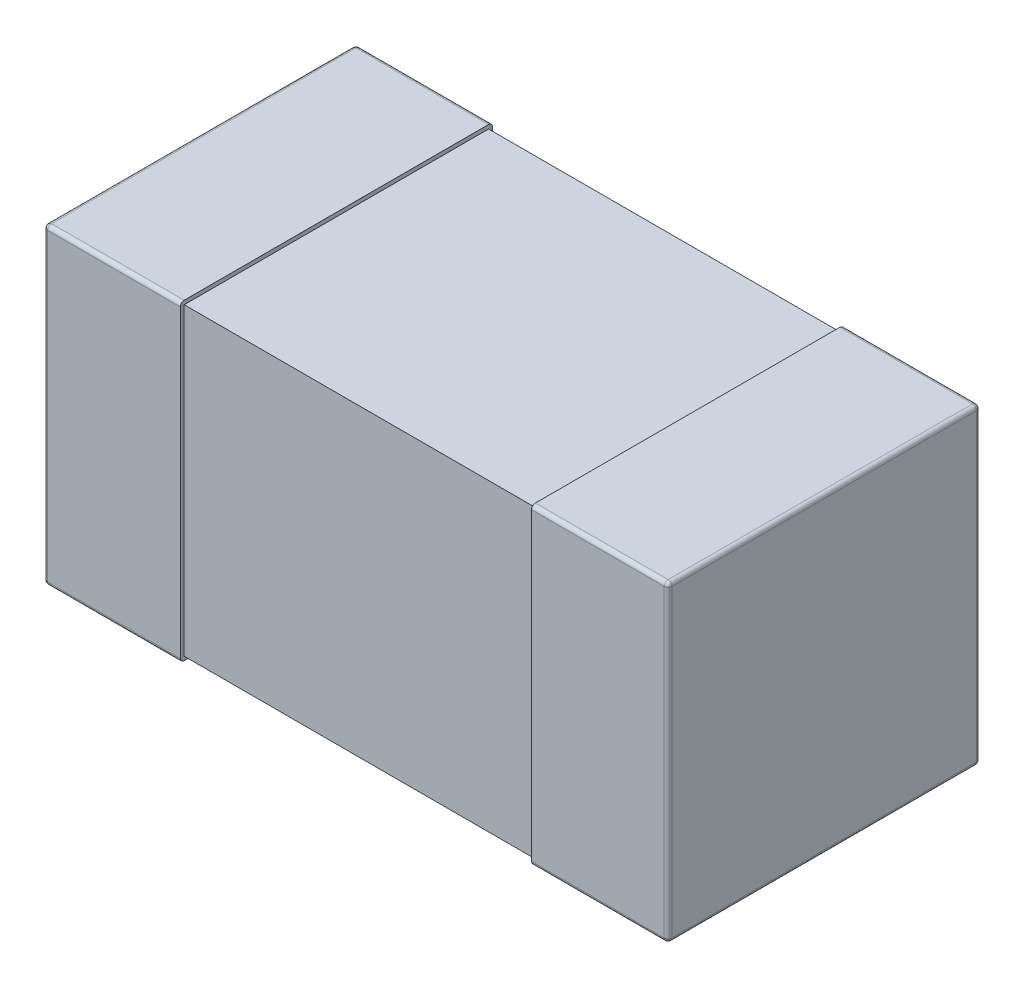
from build123d import *

# Parameters (mm, degrees)
SKETCH1_W            = 0.35
SKETCH1_H            = 0.8
THICKNESS_DEPTH      = 0.4
FILLET1_R            = 0.01
SKETCH2_W            = 0.78
SKETCH2_H            = 0.78
BOSS_EXTRUDE2_DEPTH  = 0.45
FILLET1_OF_MIRROR3_R = 0.01


with BuildPart() as part:
    # Sketch1 → THICKNESS (new body, symmetric)
    with BuildSketch(Plane(origin=(0, 0, 0), x_dir=(1, 0, 0), z_dir=(0, 1, 0))):
        with Locations((-0.625, 0)):
            Rectangle(SKETCH1_W, SKETCH1_H)
    thickness = extrude(amount=THICKNESS_DEPTH, both=True)

    # Fillet1
    fillet1_edges = [part.edges().sort_by_distance(p)[0] for p in [
        (-0.625, 0.4, -0.4),
        (-0.8, 0.4, 0),
        (-0.625, -0.4, -0.4),
        (-0.625, -0.4, 0.4),
        (-0.8, -0.4, 0),
        (-0.625, 0.4, 0.4),
        (-0.8, 0, -0.4),
        (-0.8, 0, 0.4),
    ]]
    fillet(fillet1_edges, radius=FILLET1_R)

    # Sketch2 → Boss-Extrude2 (add)
    with BuildSketch(Plane(origin=(0, 0, 0), x_dir=(0, 0, -1), z_dir=(1, 0, 0))):
        Rectangle(SKETCH2_W, SKETCH2_H)
    boss_extrude2 = extrude(amount=-BOSS_EXTRUDE2_DEPTH)

    # Mirror3: THICKNESS, Boss-Extrude2 across plane
    add(thickness.mirror(Plane(origin=(0, 0, 0), x_dir=(0, 0, 1), z_dir=(1, 0, 0))))
    add(boss_extrude2.mirror(Plane(origin=(0, 0, 0), x_dir=(0, 0, 1), z_dir=(1, 0, 0))))

    # Fillet1 of Mirror3
    fillet1_of_mirror3_edges = [part.edges().sort_by_distance(p)[0] for p in [
        (0.625, 0.4, -0.4),
        (0.8, 0.4, 0),
        (0.625, -0.4, -0.4),
        (0.625, -0.4, 0.4),
        (0.8, -0.4, 0),
        (0.625, 0.4, 0.4),
        (0.8, 0, -0.4),
        (0.8, 0, 0.4),
    ]]
    fillet(fillet1_of_mirror3_edges, radius=FILLET1_OF_MIRROR3_R)


solid = part.part
